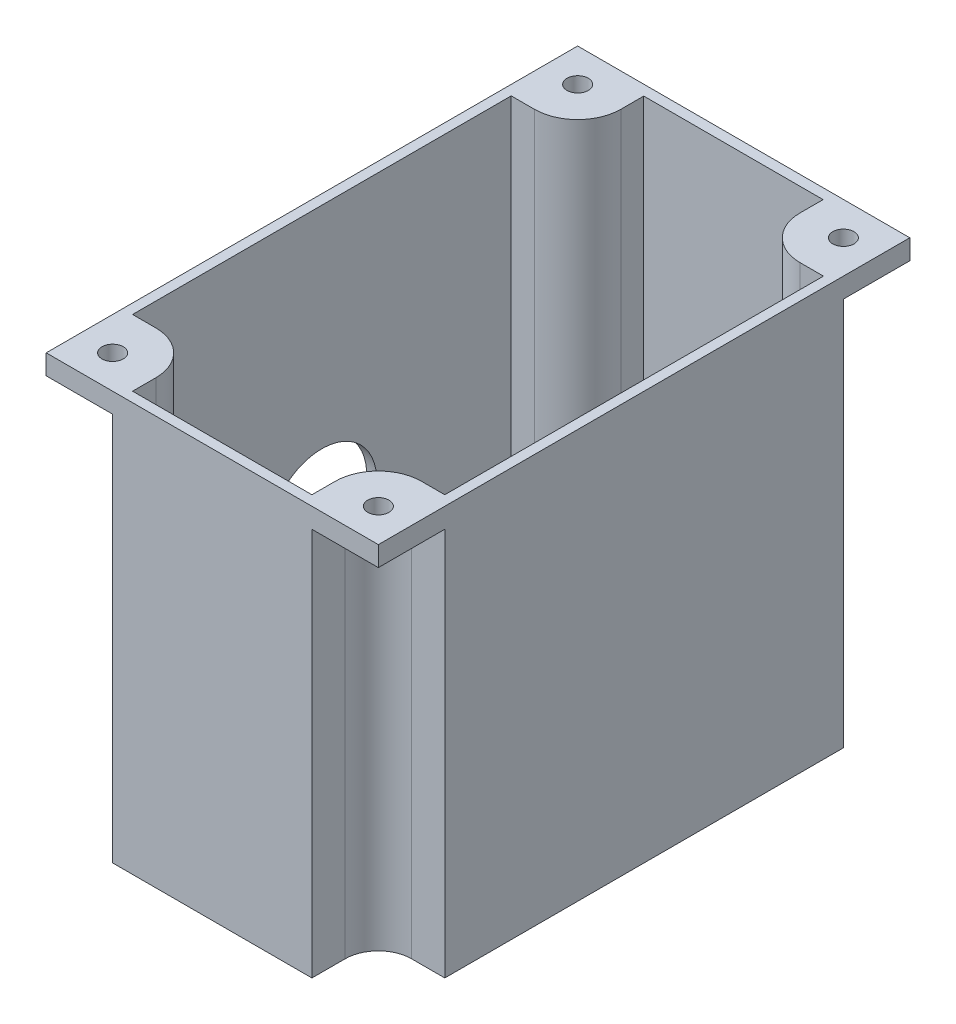
from build123d import *

# Parameters (mm, degrees)
BOSS_EXTRUDE6_DEPTH = 60
BOSS_EXTRUDE8_DEPTH = 1.5
BOSS_EXTRUDE9_DEPTH = 3
SKETCH15_R          = 1.6
CUT_EXTRUDE4_DEPTH  = 62.5
SKETCH11_R          = 8.25
CUT_EXTRUDE3_DEPTH  = 1.5


with BuildPart() as part:
    # Sketch1 → Boss-Extrude6 (new body)
    with BuildSketch(Plane(origin=(0, 0, 0), x_dir=(1, 0, 0), z_dir=(0, 1, 0))):
        with BuildLine():
            Line((-15, -35), (-15, -40))
            Line((-15, -40), (-13.5, -40))
            Line((-13.5, -40), (13.5, -40))
            Line((13.5, -40), (15, -40))
            Line((15, -40), (15, -35))
            ThreePointArc((15, -35), (16.464466094, -31.464466094), (20, -30))
            Line((20, -30), (25, -30))
            Line((25, -30), (25, -28.5))
            Line((25, -28.5), (25, 28.5))
            Line((25, 28.5), (25, 30))
            Line((25, 30), (20, 30))
            ThreePointArc((20, 30), (16.464466094, 31.464466094), (15, 35))
            Line((15, 35), (15, 40))
            Line((15, 40), (13.5, 40))
            Line((13.5, 40), (-13.5, 40))
            Line((-13.5, 40), (-15, 40))
            Line((-15, 40), (-15, 35))
            ThreePointArc((-15, 35), (-16.464466094, 31.464466094), (-20, 30))
            Line((-20, 30), (-25, 30))
            Line((-25, 30), (-25, 28.5))
            Line((-25, 28.5), (-25, -28.5))
            Line((-25, -28.5), (-25, -30))
            Line((-25, -30), (-20, -30))
            ThreePointArc((-20, -30), (-16.464466094, -31.464466094), (-15, -35))
        make_face()
        with BuildLine():
            Line((20, 28.5), (23.5, 28.5))
            Line((23.5, 28.5), (23.5, -28.5))
            Line((23.5, -28.5), (20, -28.5))
            ThreePointArc((20, -28.5), (15.403805922, -30.403805922), (13.5, -35))
            Line((13.5, -35), (13.5, -38.5))
            Line((13.5, -38.5), (-13.5, -38.5))
            Line((-13.5, -38.5), (-13.5, -35))
            ThreePointArc((-13.5, -35), (-15.403805922, -30.403805922), (-20, -28.5))
            Line((-20, -28.5), (-23.5, -28.5))
            Line((-23.5, -28.5), (-23.5, 28.5))
            Line((-23.5, 28.5), (-20, 28.5))
            ThreePointArc((-20, 28.5), (-15.403805922, 30.403805922), (-13.5, 35))
            Line((-13.5, 35), (-13.5, 38.45))
            Line((-13.5, 38.45), (13.5, 38.45))
            Line((13.5, 38.45), (13.5, 35))
            ThreePointArc((13.5, 35), (15.403805922, 30.403805922), (20, 28.5))
        make_face(mode=Mode.SUBTRACT)
    extrude(amount=BOSS_EXTRUDE6_DEPTH)

    # Sketch7 → Boss-Extrude8 (add)
    with BuildSketch(Plane.XZ):
        with BuildLine():
            Line((-15, 40), (15, 40))
            Line((15, 40), (15, 35))
            ThreePointArc((15, 35), (16.464466094, 31.464466094), (20, 30))
            Line((20, 30), (25, 30))
            Line((25, 30), (25, -30))
            Line((25, -30), (20, -30))
            ThreePointArc((20, -30), (16.464466094, -31.464466094), (15, -35))
            Line((15, -35), (15, -40))
            Line((15, -40), (-15, -40))
            Line((-15, -40), (-15, -35))
            ThreePointArc((-15, -35), (-16.464466094, -31.464466094), (-20, -30))
            Line((-20, -30), (-25, -30))
            Line((-25, -30), (-25, 30))
            Line((-25, 30), (-20, 30))
            ThreePointArc((-20, 30), (-16.464466094, 31.464466094), (-15, 35))
            Line((-15, 35), (-15, 40))
        make_face()
    extrude(amount=BOSS_EXTRUDE8_DEPTH)

    # Sketch12 → Boss-Extrude9 (add)
    with BuildSketch(Plane(origin=(0, 60, 0), x_dir=(1, 0, 0), z_dir=(0, 1, 0))):
        with BuildLine():
            Line((-25, 40), (-15, 40))
            Line((-15, 40), (-15, 35))
            ThreePointArc((-15, 35), (-16.464466094, 31.464466094), (-20, 30))
            Line((-20, 30), (-25, 30))
            Line((-25, 30), (-25, 40))
        make_face()
        with BuildLine():
            Line((15, 40), (25, 40))
            Line((25, 40), (25, 30))
            Line((25, 30), (20, 30))
            ThreePointArc((20, 30), (16.464466094, 31.464466094), (15, 35))
            Line((15, 35), (15, 40))
        make_face()
        with BuildLine():
            Line((20, -30), (25, -30))
            Line((25, -30), (25, -40))
            Line((25, -40), (15, -40))
            Line((15, -40), (15, -35))
            ThreePointArc((15, -35), (16.464466094, -31.464466094), (20, -30))
        make_face()
        with BuildLine():
            Line((-15, -40), (-25, -40))
            Line((-25, -40), (-25, -30))
            Line((-25, -30), (-20, -30))
            ThreePointArc((-20, -30), (-16.464466094, -31.464466094), (-15, -35))
            Line((-15, -35), (-15, -40))
        make_face()
    extrude(amount=-BOSS_EXTRUDE9_DEPTH)

    # Sketch15 → Cut-Extrude4 (cut, through all)
    with BuildSketch(Plane(origin=(0, 60, 0), x_dir=(1, 0, 0), z_dir=(0, 1, 0))):
        with Locations((-20, -35)):
            Circle(SKETCH15_R)
        with Locations((20, -35)):
            Circle(SKETCH15_R)
        with Locations((20, 35)):
            Circle(SKETCH15_R)
        with Locations((-20, 35)):
            Circle(SKETCH15_R)
    extrude(amount=-CUT_EXTRUDE4_DEPTH, mode=Mode.SUBTRACT)

    # Sketch11 → Cut-Extrude3 (cut)
    with BuildSketch(Plane.ZY.offset(25)):
        with Locations((0, 20)):
            Circle(SKETCH11_R)
    extrude(amount=-CUT_EXTRUDE3_DEPTH, mode=Mode.SUBTRACT)


solid = part.part
